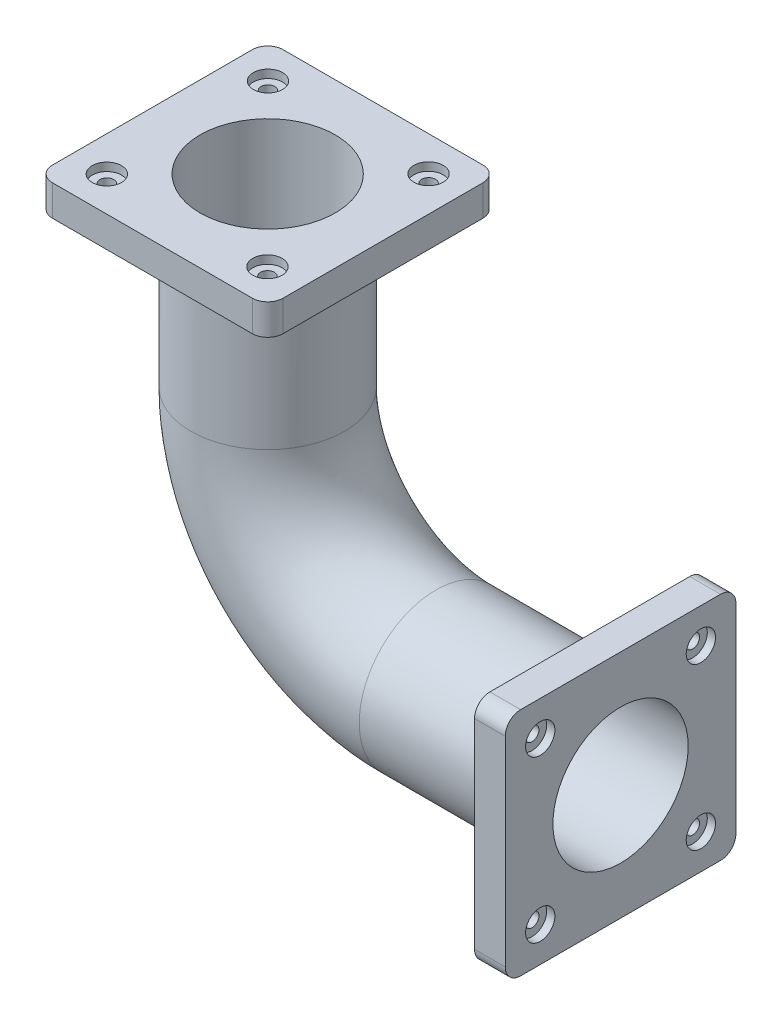
from build123d import *

# Parameters (mm, degrees)
SKETCH2_R                                           = 25
SHELL2_T                                            = -3
SKETCH3_W                                           = 75
SKETCH3_H                                           = 75
SKETCH3_R                                           = 22
BOSS_EXTRUDE1_DEPTH                                 = 10
FILLET1_R                                           = 5
CBORE_FOR_8_BINDING_HEAD_MACHINE_SCREW1_D           = 4.4958
CBORE_FOR_8_BINDING_HEAD_MACHINE_SCREW1_DEPTH       = 20
CBORE_FOR_8_BINDING_HEAD_MACHINE_SCREW1_CBORE_D     = 9.525
CBORE_FOR_8_BINDING_HEAD_MACHINE_SCREW1_CBORE_DEPTH = 2.667
CBORE_FOR_8_BINDING_HEAD_MACHINE_SCREW1_TIP         = 1.350674586
SKETCH6_W                                           = 75
SKETCH6_H                                           = 75
SKETCH6_R                                           = 22
BOSS_EXTRUDE2_DEPTH                                 = 10
FILLET2_R                                           = 5
CBORE_FOR_8_BINDING_HEAD_MACHINE_SCREW2_D           = 4.4958
CBORE_FOR_8_BINDING_HEAD_MACHINE_SCREW2_DEPTH       = 20
CBORE_FOR_8_BINDING_HEAD_MACHINE_SCREW2_CBORE_D     = 9.525
CBORE_FOR_8_BINDING_HEAD_MACHINE_SCREW2_CBORE_DEPTH = 2.667
CBORE_FOR_8_BINDING_HEAD_MACHINE_SCREW2_TIP         = 1.350674586


with BuildPart() as part:
    # Sweep1: sweep along a path in Sketch1
    with BuildLine(Plane.XY) as sweep1_path:
        Line((-55, 50), (-55, 0))
        ThreePointArc((-55, 0), (-38.890872965, -38.890872965), (0, -55))
        Line((0, -55), (50, -55))
    # Sketch2 → Sweep1 (sweep)
    with BuildSketch(Plane(origin=(-55, 50, 0), x_dir=(-1, 0, 0), z_dir=(0, -1, 0))):
        with Locations((-0.233587872, 0)):
            Circle(SKETCH2_R)
    sweep(path=sweep1_path.line)

    # Shell2
    shell2_openings = [part.faces().sort_by_distance(p)[0] for p in [
        (50, -54.766412128, 0),
        (-54.766412128, 50, 0),
    ]]
    offset(amount=SHELL2_T, openings=shell2_openings, kind=Kind.INTERSECTION)

    # Sketch3 → Boss-Extrude1 (add)
    with BuildSketch(Plane(origin=(0, 50, 0), x_dir=(1, 0, 0), z_dir=(0, 1, 0))):
        with Locations((-54.766412128, 0)):
            Rectangle(SKETCH3_W, SKETCH3_H)
        with Locations(Location((-54.766412128, 0, 0), (0, 0, 180))):
            Circle(SKETCH3_R, mode=Mode.SUBTRACT)
    extrude(amount=BOSS_EXTRUDE1_DEPTH)

    # Fillet1
    fillet1_edges = [part.edges().sort_by_distance(p)[0] for p in [
        (-17.266412128, 55, 37.5),
        (-17.266412128, 55, -37.5),
        (-92.266412128, 55, -37.5),
        (-92.266412128, 55, 37.5),
    ]]
    fillet(fillet1_edges, radius=FILLET1_R)

    # CBORE for #8 Binding Head Machine Screw1
    with Locations(Plane(origin=(-80.88402288, 60, -26.197803089), x_dir=(0, 0, 1), z_dir=(0, 1, 0))):
        with Locations((0, 0), (0, 52.235221503), (52.395606178, 0), (52.395606178, 52.235221503)):
            CounterBoreHole(CBORE_FOR_8_BINDING_HEAD_MACHINE_SCREW1_D / 2, CBORE_FOR_8_BINDING_HEAD_MACHINE_SCREW1_CBORE_D / 2, CBORE_FOR_8_BINDING_HEAD_MACHINE_SCREW1_CBORE_DEPTH, depth=CBORE_FOR_8_BINDING_HEAD_MACHINE_SCREW1_DEPTH)
            with Locations((0, 0, -(CBORE_FOR_8_BINDING_HEAD_MACHINE_SCREW1_DEPTH + CBORE_FOR_8_BINDING_HEAD_MACHINE_SCREW1_TIP / 2))):  # 118° drill point
                Cone(0, CBORE_FOR_8_BINDING_HEAD_MACHINE_SCREW1_D / 2, CBORE_FOR_8_BINDING_HEAD_MACHINE_SCREW1_TIP, mode=Mode.SUBTRACT)

    # Sketch6 → Boss-Extrude2 (add)
    with BuildSketch(Plane(origin=(50, 0, 0), x_dir=(0, 0, -1), z_dir=(1, 0, 0))):
        with Locations((0, -54.766412128)):
            Rectangle(SKETCH6_W, SKETCH6_H)
        with Locations((0, -54.766412128)):
            Circle(SKETCH6_R, mode=Mode.SUBTRACT)
    extrude(amount=BOSS_EXTRUDE2_DEPTH)

    # Fillet2
    fillet2_edges = [part.edges().sort_by_distance(p)[0] for p in [
        (55, -92.266412128, -37.5),
        (55, -17.266412128, -37.5),
        (55, -17.266412128, 37.5),
        (55, -92.266412128, 37.5),
    ]]
    fillet(fillet2_edges, radius=FILLET2_R)

    # CBORE for #8 Binding Head Machine Screw2
    with Locations(Plane(origin=(60, 0, 0), x_dir=(0, 0, -1), z_dir=(1, 0, 0))):
        with Locations((-26.12, -80.966412128), (-26.12, -28.566412128), (26.12, -28.566412128), (26.12, -80.966412128)):
            CounterBoreHole(CBORE_FOR_8_BINDING_HEAD_MACHINE_SCREW2_D / 2, CBORE_FOR_8_BINDING_HEAD_MACHINE_SCREW2_CBORE_D / 2, CBORE_FOR_8_BINDING_HEAD_MACHINE_SCREW2_CBORE_DEPTH, depth=CBORE_FOR_8_BINDING_HEAD_MACHINE_SCREW2_DEPTH)
            with Locations((0, 0, -(CBORE_FOR_8_BINDING_HEAD_MACHINE_SCREW2_DEPTH + CBORE_FOR_8_BINDING_HEAD_MACHINE_SCREW2_TIP / 2))):  # 118° drill point
                Cone(0, CBORE_FOR_8_BINDING_HEAD_MACHINE_SCREW2_D / 2, CBORE_FOR_8_BINDING_HEAD_MACHINE_SCREW2_TIP, mode=Mode.SUBTRACT)


solid = part.part
